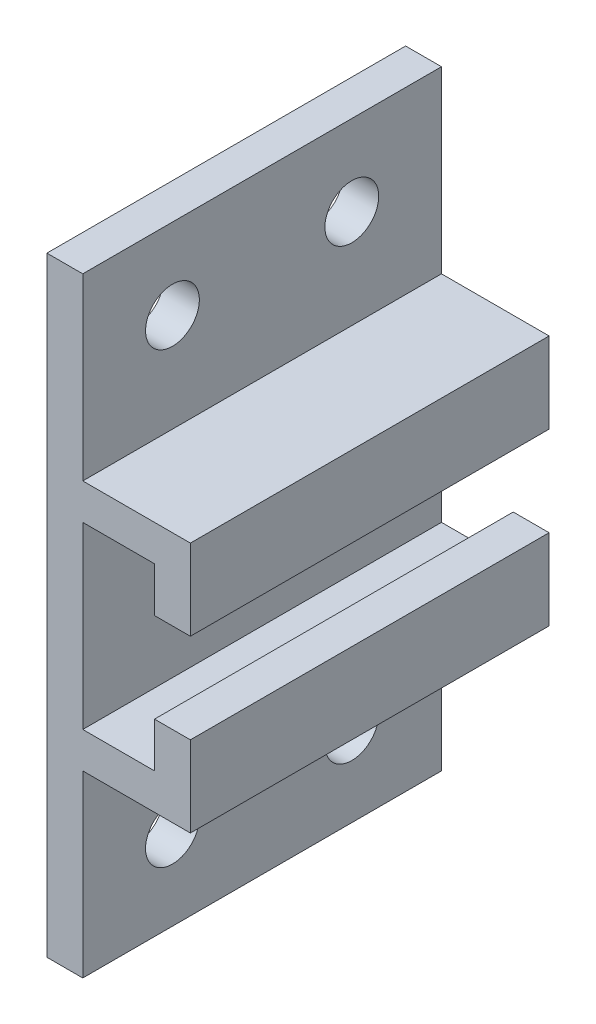
from build123d import *

# Parameters (mm, degrees)
MAIN_EXTRUSION_DEPTH = 20
WHOLES_R             = 1.5
WHOLE_REMOVAL_DEPTH  = 9


with BuildPart() as part:
    # Main → Main Extrusion (new body)
    with BuildSketch(Plane.XY):
        Polygon((0, 17), (0, -17), (2, -17), (2, -7), (8, -7), (8, -2.5), (6, -2.5), (6, -5), (2, -5), (2, 5), (6, 5), (6, 2.5), (8, 2.5), (8, 7), (2, 7), (2, 17), align=None)
    extrude(amount=MAIN_EXTRUSION_DEPTH)

    # Wholes → Whole Removal (cut, through all)
    with BuildSketch(Plane.ZY):
        with Locations((5, 12.5)):
            Circle(WHOLES_R)
        with Locations((5, -12.5)):
            Circle(WHOLES_R)
        with Locations((15, -12.5)):
            Circle(WHOLES_R)
        with Locations((15, 12.5)):
            Circle(WHOLES_R)
    extrude(amount=-WHOLE_REMOVAL_DEPTH, mode=Mode.SUBTRACT)


solid = part.part
